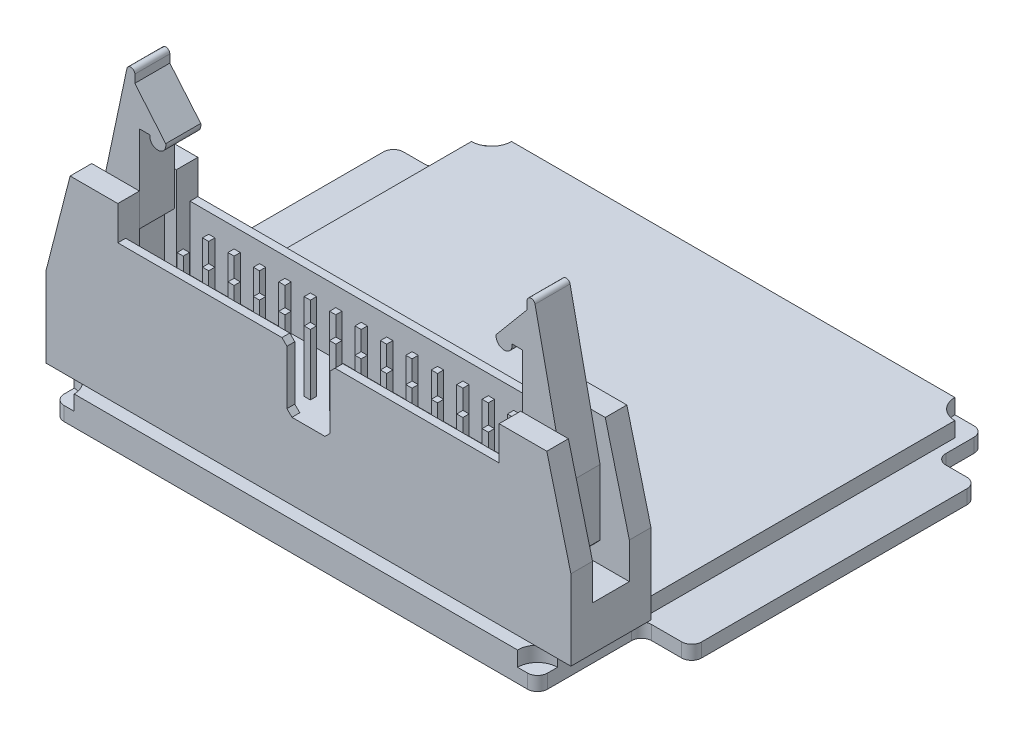
from build123d import *

# Parameters (mm, degrees)
BOSS_EXTRUDE1_DEPTH      = 4
BOSS_EXTRUDE1_DEPTH_BACK = 4
SKETCH2_W                = 38.1
SKETCH2_H                = 6.43
CUT_EXTRUDE1_DEPTH       = 6.4
CUT_EXTRUDE2_DEPTH       = 1.5
CUT_EXTRUDE3_DEPTH       = 7.2
CUT_EXTRUDE3_DEPTH_BACK  = 7.2
SKETCH4_W                = 3.68
SKETCH4_H                = 13
CUT_EXTRUDE4_DEPTH       = 7.2
CUT_EXTRUDE4_DEPTH_BACK  = 7.2
SKETCH5_W                = 3.68
SKETCH5_H                = 13
BOSS_EXTRUDE2_DEPTH      = 3.8
BOSS_EXTRUDE2_DEPTH_BACK = 3.8
SKETCH6_R                = 0.5
BOSS_EXTRUDE3_DEPTH      = 1.75
BOSS_EXTRUDE3_DEPTH_BACK = 1.75
BOSS_EXTRUDE4_DEPTH      = 1.9
BOSS_EXTRUDE4_DEPTH_BACK = 1.9
SKETCH8_R                = 0.5
BOSS_EXTRUDE5_DEPTH      = 1.75
BOSS_EXTRUDE5_DEPTH_BACK = 1.75
SKETCH10_W               = 0.62
SKETCH10_H               = 0.62
BOSS_EXTRUDE6_DEPTH      = 6.1
SKETCH11_W               = 0.62
SKETCH11_H               = 0.62
BOSS_EXTRUDE7_DEPTH      = 6.1
SKETCH12_W               = 0.62
SKETCH12_H               = 0.62
BOSS_EXTRUDE8_DEPTH      = 6.1
SKETCH13_W               = 0.62
SKETCH13_H               = 0.62
BOSS_EXTRUDE9_DEPTH      = 6.1
SKETCH14_W               = 0.62
SKETCH14_H               = 0.62
BOSS_EXTRUDE10_DEPTH     = 6.1
SKETCH15_W               = 0.62
SKETCH15_H               = 0.62
BOSS_EXTRUDE11_DEPTH     = 6.1
SKETCH16_W               = 0.62
SKETCH16_H               = 0.62
BOSS_EXTRUDE12_DEPTH     = 6.1
SKETCH17_W               = 0.62
SKETCH17_H               = 0.62
BOSS_EXTRUDE13_DEPTH     = 6.1
SKETCH18_W               = 0.62
SKETCH18_H               = 0.62
BOSS_EXTRUDE14_DEPTH     = 6.1
SKETCH19_W               = 0.62
SKETCH19_H               = 0.62
BOSS_EXTRUDE15_DEPTH     = 6.1
SKETCH20_W               = 0.62
SKETCH20_H               = 0.62
BOSS_EXTRUDE16_DEPTH     = 6.1
SKETCH21_W               = 0.62
SKETCH21_H               = 0.62
BOSS_EXTRUDE17_DEPTH     = 6.1
SKETCH22_W               = 0.62
SKETCH22_H               = 0.62
BOSS_EXTRUDE18_DEPTH     = 6.1
SKETCH23_W               = 0.62
SKETCH23_H               = 0.62
BOSS_EXTRUDE19_DEPTH     = 6.1
SKETCH24_W               = 0.62
SKETCH24_H               = 0.62
BOSS_EXTRUDE20_DEPTH     = 6.1
SKETCH25_W               = 0.62
SKETCH25_H               = 0.62
BOSS_EXTRUDE21_DEPTH     = 6.1
SKETCH26_W               = 0.62
SKETCH26_H               = 0.62
BOSS_EXTRUDE22_DEPTH     = 6.1
SKETCH27_W               = 0.62
SKETCH27_H               = 0.62
BOSS_EXTRUDE23_DEPTH     = 6.1
SKETCH28_W               = 0.62
SKETCH28_H               = 0.62
BOSS_EXTRUDE24_DEPTH     = 6.1
SKETCH29_W               = 0.62
SKETCH29_H               = 0.62
BOSS_EXTRUDE25_DEPTH     = 6.1
SKETCH30_W               = 0.62
SKETCH30_H               = 0.62
BOSS_EXTRUDE26_DEPTH     = 6.1
SKETCH31_W               = 0.62
SKETCH31_H               = 0.62
BOSS_EXTRUDE27_DEPTH     = 6.1
SKETCH32_W               = 0.62
SKETCH32_H               = 0.62
BOSS_EXTRUDE28_DEPTH     = 6.1
SKETCH33_W               = 0.62
SKETCH33_H               = 0.62
BOSS_EXTRUDE29_DEPTH     = 6.1
SKETCH34_W               = 0.62
SKETCH34_H               = 0.62
BOSS_EXTRUDE30_DEPTH     = 6.1
SKETCH35_W               = 0.62
SKETCH35_H               = 0.62
BOSS_EXTRUDE31_DEPTH     = 6.1
BOSS_EXTRUDE32_DEPTH     = 1.5
BOSS_EXTRUDE33_DEPTH     = 1.4


with BuildPart() as part:
    # Sketch1 → Boss-Extrude1 (new, two sides: drawn at the far end of the back side and taken through both)
    with BuildSketch(Plane.XY.offset(-BOSS_EXTRUDE1_DEPTH_BACK)):
        Polygon((-26.225, 8), (-26.225, 0), (26.225, 0), (26.225, 8), (23.815, 17.4), (19.05, 17.4), (19.05, 14), (-19.05, 14), (-19.05, 17.4), (-23.815, 17.4), align=None)
    extrude(amount=BOSS_EXTRUDE1_DEPTH + BOSS_EXTRUDE1_DEPTH_BACK)

    # Sketch2 → Cut-Extrude1 (cut)
    with BuildSketch(Plane(origin=(0, 14, 0), x_dir=(1, 0, 0), z_dir=(0, 1, 0))):
        Rectangle(SKETCH2_W, SKETCH2_H)
    extrude(amount=-CUT_EXTRUDE1_DEPTH, mode=Mode.SUBTRACT)

    # Sketch3 → Cut-Extrude2 (cut)
    with BuildSketch(Plane.XY.offset(4.075)):
        Polygon((-2.65, 14), (-2.15, 13.5), (-2.15, 8.1), (-1.65, 7.6), (1.65, 7.6), (2.15, 8.1), (2.15, 13.5), (2.65, 14), align=None)
    extrude(amount=-CUT_EXTRUDE2_DEPTH, mode=Mode.SUBTRACT)

    # Sketch4 → Cut-Extrude3 (cut, two sides: drawn at the far end of the back side and taken through both)
    with BuildSketch(Plane(origin=(26.225, 0, 0), x_dir=(0, 0, -1), z_dir=(1, 0, 0)).offset(-CUT_EXTRUDE3_DEPTH_BACK)):
        with Locations((0, 10.9)):
            Rectangle(SKETCH4_W, SKETCH4_H)
    extrude(amount=CUT_EXTRUDE3_DEPTH + CUT_EXTRUDE3_DEPTH_BACK, mode=Mode.SUBTRACT)

    # Sketch5 → Cut-Extrude4 (cut, two sides: drawn at the far end of the back side and taken through both)
    with BuildSketch(Plane(origin=(-26.225, 0, 0), x_dir=(0, 0, -1), z_dir=(1, 0, 0)).offset(-CUT_EXTRUDE4_DEPTH_BACK)):
        with Locations((0, 10.9)):
            Rectangle(SKETCH5_W, SKETCH5_H)
    extrude(amount=CUT_EXTRUDE4_DEPTH + CUT_EXTRUDE4_DEPTH_BACK, mode=Mode.SUBTRACT)

    # Sketch6 → Boss-Extrude2 (add, two sides: drawn at the far end of the back side and taken through both)
    with BuildSketch(Plane.XY.offset(-BOSS_EXTRUDE2_DEPTH_BACK)):
        with Locations((22.225, 9.86)):
            Circle(SKETCH6_R)
    extrude(amount=BOSS_EXTRUDE2_DEPTH + BOSS_EXTRUDE2_DEPTH_BACK)

    # Sketch7 → Boss-Extrude3 (add, two sides: drawn at the far end of the back side and taken through both)
    with BuildSketch(Plane.XY.offset(-BOSS_EXTRUDE3_DEPTH_BACK)):
        with BuildLine():
            Line((18.100152425, 22.694506131), (19.155, 22.694506131))
            Line((19.155, 22.694506131), (19.155, 14.023))
            Line((19.155, 14.023), (20.155, 14.023))
            Line((20.155, 14.023), (20.155, 6.62026486))
            ThreePointArc((20.155, 6.62026486), (21.77, 5.8), (23.385, 6.62026486))
            Line((23.385, 6.62026486), (23.385, 13.162181097))
            Line((23.385, 13.162181097), (20.391302756, 27.282958744))
            ThreePointArc((20.391302756, 27.282958744), (19.9582933, 27.597819747), (19.6, 27.2))
            Line((19.6, 27.2), (19.6, 26.4))
            Line((19.6, 26.4), (16.514619474, 22.722986673))
            ThreePointArc((16.514619474, 22.722986673), (17.29056123, 21.772101776), (18.100152425, 22.694506131))
        make_face()
    extrude(amount=BOSS_EXTRUDE3_DEPTH + BOSS_EXTRUDE3_DEPTH_BACK)

    # Sketch8 → Boss-Extrude4 (add, two sides: drawn at the far end of the back side and taken through both)
    with BuildSketch(Plane.XY.offset(-BOSS_EXTRUDE4_DEPTH_BACK)):
        with Locations((-22.225, 9.86)):
            Circle(SKETCH8_R)
    extrude(amount=BOSS_EXTRUDE4_DEPTH + BOSS_EXTRUDE4_DEPTH_BACK)

    # Sketch9 → Boss-Extrude5 (add, two sides: drawn at the far end of the back side and taken through both)
    with BuildSketch(Plane.XY.offset(-BOSS_EXTRUDE5_DEPTH_BACK)):
        with BuildLine():
            Line((-23.385, 13.162181097), (-23.385, 6.62026486))
            ThreePointArc((-23.385, 6.62026486), (-21.77, 5.8), (-20.155, 6.62026486))
            Line((-20.155, 6.62026486), (-20.155, 14.023))
            Line((-20.155, 14.023), (-19.155, 14.023))
            Line((-19.155, 14.023), (-19.155, 22.694506131))
            Line((-19.155, 22.694506131), (-18.100152425, 22.694506131))
            ThreePointArc((-18.100152425, 22.694506131), (-17.29056123, 21.772101776), (-16.514619474, 22.722986673))
            Line((-16.514619474, 22.722986673), (-19.6, 26.4))
            Line((-19.6, 26.4), (-19.6, 27.2))
            ThreePointArc((-19.6, 27.2), (-19.9582933, 27.597819747), (-20.391302756, 27.282958744))
            Line((-20.391302756, 27.282958744), (-23.385, 13.162181097))
        make_face()
    extrude(amount=BOSS_EXTRUDE5_DEPTH + BOSS_EXTRUDE5_DEPTH_BACK)

    # Sketch10 → Boss-Extrude6 (add)
    with BuildSketch(Plane(origin=(0, 7.6, 0), x_dir=(1, 0, 0), z_dir=(0, 1, 0))):
        with Locations((-15.24, -1.27)):
            Rectangle(SKETCH10_W, SKETCH10_H)
    extrude(amount=BOSS_EXTRUDE6_DEPTH)

    # Sketch11 → Boss-Extrude7 (add)
    with BuildSketch(Plane(origin=(0, 7.6, 0), x_dir=(1, 0, 0), z_dir=(0, 1, 0))):
        with Locations((-12.7, -1.27)):
            Rectangle(SKETCH11_W, SKETCH11_H)
    extrude(amount=BOSS_EXTRUDE7_DEPTH)

    # Sketch12 → Boss-Extrude8 (add)
    with BuildSketch(Plane(origin=(0, 7.6, 0), x_dir=(1, 0, 0), z_dir=(0, 1, 0))):
        with Locations((-10.16, -1.27)):
            Rectangle(SKETCH12_W, SKETCH12_H)
    extrude(amount=BOSS_EXTRUDE8_DEPTH)

    # Sketch13 → Boss-Extrude9 (add)
    with BuildSketch(Plane(origin=(0, 7.6, 0), x_dir=(1, 0, 0), z_dir=(0, 1, 0))):
        with Locations((-7.62, -1.27)):
            Rectangle(SKETCH13_W, SKETCH13_H)
    extrude(amount=BOSS_EXTRUDE9_DEPTH)

    # Sketch14 → Boss-Extrude10 (add)
    with BuildSketch(Plane(origin=(0, 7.6, 0), x_dir=(1, 0, 0), z_dir=(0, 1, 0))):
        with Locations((-5.08, -1.27)):
            Rectangle(SKETCH14_W, SKETCH14_H)
    extrude(amount=BOSS_EXTRUDE10_DEPTH)

    # Sketch15 → Boss-Extrude11 (add)
    with BuildSketch(Plane(origin=(0, 7.6, 0), x_dir=(1, 0, 0), z_dir=(0, 1, 0))):
        with Locations((-2.54, -1.27)):
            Rectangle(SKETCH15_W, SKETCH15_H)
    extrude(amount=BOSS_EXTRUDE11_DEPTH)

    # Sketch16 → Boss-Extrude12 (add)
    with BuildSketch(Plane(origin=(0, 7.6, 0), x_dir=(1, 0, 0), z_dir=(0, 1, 0))):
        with Locations((0, -1.27)):
            Rectangle(SKETCH16_W, SKETCH16_H)
    extrude(amount=BOSS_EXTRUDE12_DEPTH)

    # Sketch17 → Boss-Extrude13 (add)
    with BuildSketch(Plane(origin=(0, 7.6, 0), x_dir=(1, 0, 0), z_dir=(0, 1, 0))):
        with Locations((2.54, -1.27)):
            Rectangle(SKETCH17_W, SKETCH17_H)
    extrude(amount=BOSS_EXTRUDE13_DEPTH)

    # Sketch18 → Boss-Extrude14 (add)
    with BuildSketch(Plane(origin=(0, 7.6, 0), x_dir=(1, 0, 0), z_dir=(0, 1, 0))):
        with Locations((5.08, -1.27)):
            Rectangle(SKETCH18_W, SKETCH18_H)
    extrude(amount=BOSS_EXTRUDE14_DEPTH)

    # Sketch19 → Boss-Extrude15 (add)
    with BuildSketch(Plane(origin=(0, 7.6, 0), x_dir=(1, 0, 0), z_dir=(0, 1, 0))):
        with Locations((7.62, -1.27)):
            Rectangle(SKETCH19_W, SKETCH19_H)
    extrude(amount=BOSS_EXTRUDE15_DEPTH)

    # Sketch20 → Boss-Extrude16 (add)
    with BuildSketch(Plane(origin=(0, 7.6, 0), x_dir=(1, 0, 0), z_dir=(0, 1, 0))):
        with Locations((10.16, -1.27)):
            Rectangle(SKETCH20_W, SKETCH20_H)
    extrude(amount=BOSS_EXTRUDE16_DEPTH)

    # Sketch21 → Boss-Extrude17 (add)
    with BuildSketch(Plane(origin=(0, 7.6, 0), x_dir=(1, 0, 0), z_dir=(0, 1, 0))):
        with Locations((12.7, -1.27)):
            Rectangle(SKETCH21_W, SKETCH21_H)
    extrude(amount=BOSS_EXTRUDE17_DEPTH)

    # Sketch22 → Boss-Extrude18 (add)
    with BuildSketch(Plane(origin=(0, 7.6, 0), x_dir=(1, 0, 0), z_dir=(0, 1, 0))):
        with Locations((15.24, -1.27)):
            Rectangle(SKETCH22_W, SKETCH22_H)
    extrude(amount=BOSS_EXTRUDE18_DEPTH)

    # Sketch23 → Boss-Extrude19 (add)
    with BuildSketch(Plane(origin=(0, 7.6, 0), x_dir=(1, 0, 0), z_dir=(0, 1, 0))):
        with Locations((-15.24, 1.27)):
            Rectangle(SKETCH23_W, SKETCH23_H)
    extrude(amount=BOSS_EXTRUDE19_DEPTH)

    # Sketch24 → Boss-Extrude20 (add)
    with BuildSketch(Plane(origin=(0, 7.6, 0), x_dir=(1, 0, 0), z_dir=(0, 1, 0))):
        with Locations((-12.7, 1.27)):
            Rectangle(SKETCH24_W, SKETCH24_H)
    extrude(amount=BOSS_EXTRUDE20_DEPTH)

    # Sketch25 → Boss-Extrude21 (add)
    with BuildSketch(Plane(origin=(0, 7.6, 0), x_dir=(1, 0, 0), z_dir=(0, 1, 0))):
        with Locations((-10.16, 1.27)):
            Rectangle(SKETCH25_W, SKETCH25_H)
    extrude(amount=BOSS_EXTRUDE21_DEPTH)

    # Sketch26 → Boss-Extrude22 (add)
    with BuildSketch(Plane(origin=(0, 7.6, 0), x_dir=(1, 0, 0), z_dir=(0, 1, 0))):
        with Locations((-7.62, 1.27)):
            Rectangle(SKETCH26_W, SKETCH26_H)
    extrude(amount=BOSS_EXTRUDE22_DEPTH)

    # Sketch27 → Boss-Extrude23 (add)
    with BuildSketch(Plane(origin=(0, 7.6, 0), x_dir=(1, 0, 0), z_dir=(0, 1, 0))):
        with Locations((-5.08, 1.27)):
            Rectangle(SKETCH27_W, SKETCH27_H)
    extrude(amount=BOSS_EXTRUDE23_DEPTH)

    # Sketch28 → Boss-Extrude24 (add)
    with BuildSketch(Plane(origin=(0, 7.6, 0), x_dir=(1, 0, 0), z_dir=(0, 1, 0))):
        with Locations((-2.54, 1.27)):
            Rectangle(SKETCH28_W, SKETCH28_H)
    extrude(amount=BOSS_EXTRUDE24_DEPTH)

    # Sketch29 → Boss-Extrude25 (add)
    with BuildSketch(Plane(origin=(0, 7.6, 0), x_dir=(1, 0, 0), z_dir=(0, 1, 0))):
        with Locations((0, 1.27)):
            Rectangle(SKETCH29_W, SKETCH29_H)
    extrude(amount=BOSS_EXTRUDE25_DEPTH)

    # Sketch30 → Boss-Extrude26 (add)
    with BuildSketch(Plane(origin=(0, 7.6, 0), x_dir=(1, 0, 0), z_dir=(0, 1, 0))):
        with Locations((2.54, 1.27)):
            Rectangle(SKETCH30_W, SKETCH30_H)
    extrude(amount=BOSS_EXTRUDE26_DEPTH)

    # Sketch31 → Boss-Extrude27 (add)
    with BuildSketch(Plane(origin=(0, 7.6, 0), x_dir=(1, 0, 0), z_dir=(0, 1, 0))):
        with Locations((5.08, 1.27)):
            Rectangle(SKETCH31_W, SKETCH31_H)
    extrude(amount=BOSS_EXTRUDE27_DEPTH)

    # Sketch32 → Boss-Extrude28 (add)
    with BuildSketch(Plane(origin=(0, 7.6, 0), x_dir=(1, 0, 0), z_dir=(0, 1, 0))):
        with Locations((7.62, 1.27)):
            Rectangle(SKETCH32_W, SKETCH32_H)
    extrude(amount=BOSS_EXTRUDE28_DEPTH)

    # Sketch33 → Boss-Extrude29 (add)
    with BuildSketch(Plane(origin=(0, 7.6, 0), x_dir=(1, 0, 0), z_dir=(0, 1, 0))):
        with Locations((10.16, 1.27)):
            Rectangle(SKETCH33_W, SKETCH33_H)
    extrude(amount=BOSS_EXTRUDE29_DEPTH)

    # Sketch34 → Boss-Extrude30 (add)
    with BuildSketch(Plane(origin=(0, 7.6, 0), x_dir=(1, 0, 0), z_dir=(0, 1, 0))):
        with Locations((12.7, 1.27)):
            Rectangle(SKETCH34_W, SKETCH34_H)
    extrude(amount=BOSS_EXTRUDE30_DEPTH)

    # Sketch35 → Boss-Extrude31 (add)
    with BuildSketch(Plane(origin=(0, 7.6, 0), x_dir=(1, 0, 0), z_dir=(0, 1, 0))):
        with Locations((15.24, 1.27)):
            Rectangle(SKETCH35_W, SKETCH35_H)
    extrude(amount=BOSS_EXTRUDE31_DEPTH)

    # Sketch36 → Boss-Extrude32 (add)
    with BuildSketch(Plane(origin=(0, 0, 0), x_dir=(1, 0, 0), z_dir=(0, 1, 0))):
        with BuildLine():
            Line((-22.15, -5.26), (22.15, -5.26))
            ThreePointArc((22.15, -5.26), (22.735786438, -3.845786438), (24.15, -3.26))
            Line((24.15, -3.26), (24.15, 36.44))
            ThreePointArc((24.15, 36.44), (22.735786438, 37.025786438), (22.15, 38.44))
            Line((22.15, 38.44), (-22.15, 38.44))
            ThreePointArc((-22.15, 38.44), (-22.735786438, 37.025786438), (-24.15, 36.44))
            Line((-24.15, 36.44), (-24.15, -3.26))
            ThreePointArc((-24.15, -3.26), (-22.735786438, -3.845786438), (-22.15, -5.26))
        make_face()
    extrude(amount=-BOSS_EXTRUDE32_DEPTH)

    # Sketch37 → Boss-Extrude33 (add)
    with BuildSketch(Plane(origin=(0, -1.5, 0), x_dir=(1, 0, 0), z_dir=(0, 1, 0))):
        with BuildLine():
            Line((-28.15, 5.14), (-25.15, 5.14))
            ThreePointArc((-25.15, 5.14), (-24.442893219, 4.847106781), (-24.15, 4.14))
            Line((-24.15, 4.14), (-24.15, -4.26))
            ThreePointArc((-24.15, -4.26), (-23.857106781, -4.967106781), (-23.15, -5.26))
            Line((-23.15, -5.26), (23.15, -5.26))
            ThreePointArc((23.15, -5.26), (23.857106781, -4.967106781), (24.15, -4.26))
            Line((24.15, -4.26), (24.15, 4.14))
            ThreePointArc((24.15, 4.14), (24.442893219, 4.847106781), (25.15, 5.14))
            Line((25.15, 5.14), (28.15, 5.14))
            ThreePointArc((28.15, 5.14), (28.857106781, 5.432893219), (29.15, 6.14))
            Line((29.15, 6.14), (29.15, 32.64))
            ThreePointArc((29.15, 32.64), (28.857106781, 33.347106781), (28.15, 33.64))
            Line((28.15, 33.64), (26.05, 33.64))
            ThreePointArc((26.05, 33.64), (25.342893219, 33.932893219), (25.05, 34.64))
            Line((25.05, 34.64), (25.05, 37.44))
            ThreePointArc((25.05, 37.44), (24.757106781, 38.147106781), (24.05, 38.44))
            Line((24.05, 38.44), (-24.05, 38.44))
            ThreePointArc((-24.05, 38.44), (-24.757106781, 38.147106781), (-25.05, 37.44))
            Line((-25.05, 37.44), (-25.05, 34.64))
            ThreePointArc((-25.05, 34.64), (-25.342893219, 33.932893219), (-26.05, 33.64))
            Line((-26.05, 33.64), (-28.15, 33.64))
            ThreePointArc((-28.15, 33.64), (-28.857106781, 33.347106781), (-29.15, 32.64))
            Line((-29.15, 32.64), (-29.15, 6.14))
            ThreePointArc((-29.15, 6.14), (-28.857106781, 5.432893219), (-28.15, 5.14))
        make_face()
    extrude(amount=-BOSS_EXTRUDE33_DEPTH)


solid = part.part
